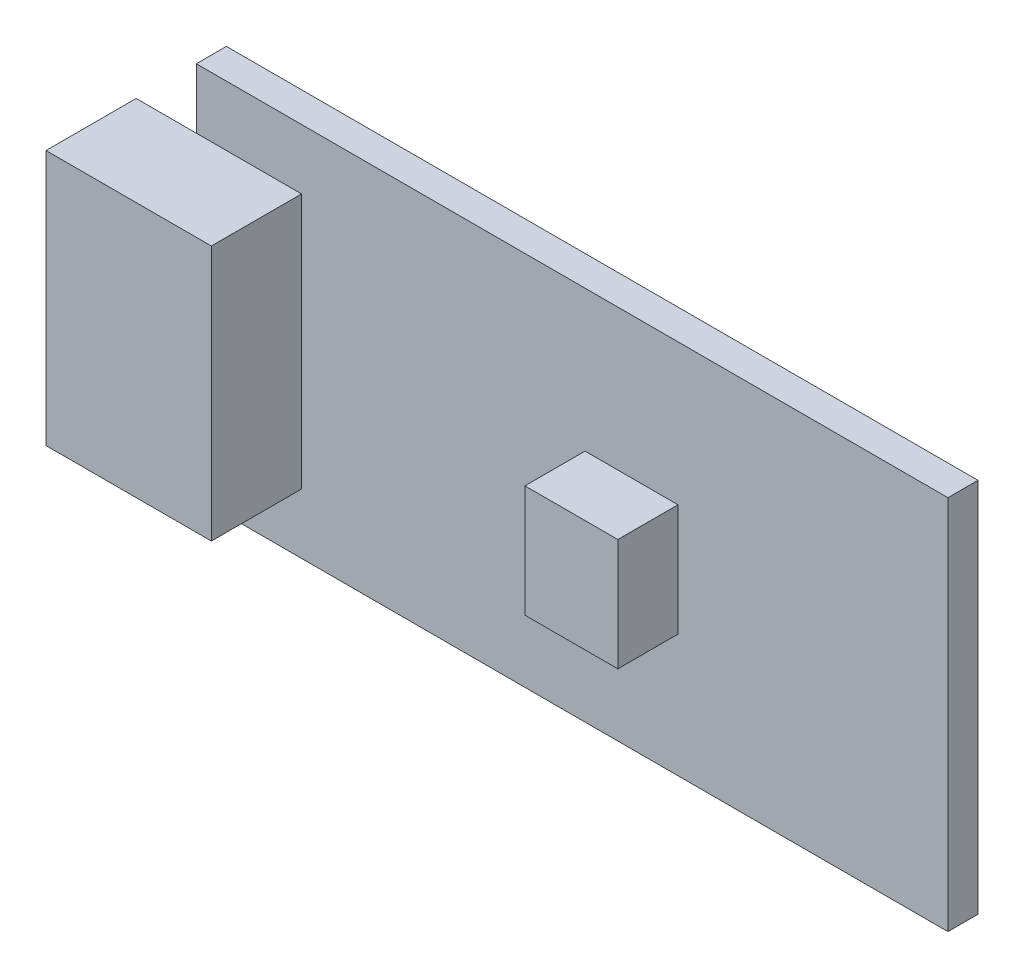
from build123d import *

# Parameters (mm, degrees)
SKIZZE1_W                       = 25
SKIZZE1_H                       = 12.5
SKIZZE1_W_2                     = 3.091607018
SKIZZE1_H_2                     = 3.725771618
AUFSATZ_LINEAR_AUSTRAGEN1_DEPTH = 1
SKIZZE1_2_W                     = 3.091607018
SKIZZE1_2_H                     = 3.725771618
AUFSATZ_LINEAR_AUSTRAGEN2_DEPTH = 3
SKIZZE2_W                       = 5.5
SKIZZE2_H                       = 8.5
AUFSATZ_LINEAR_AUSTRAGEN3_DEPTH = 3


with BuildPart() as part:
    # Skizze1 → Aufsatz-Linear austragen1 (new body)
    with BuildSketch(Plane.XY):
        with Locations((12.5, 6.25)):
            Rectangle(SKIZZE1_W, SKIZZE1_H)
        with Locations((14.475260973, 5.942942992)):
            Rectangle(SKIZZE1_W_2, SKIZZE1_H_2, mode=Mode.SUBTRACT)
    extrude(amount=AUFSATZ_LINEAR_AUSTRAGEN1_DEPTH)

    # Skizze1_2 → Aufsatz-Linear austragen2 (add)
    with BuildSketch(Plane.XY):
        with Locations((14.475260973, 5.942942992)):
            Rectangle(SKIZZE1_2_W, SKIZZE1_2_H)
    extrude(amount=AUFSATZ_LINEAR_AUSTRAGEN2_DEPTH)

    # Skizze2 → Aufsatz-Linear austragen3 (add)
    with BuildSketch(Plane.XY.offset(1)):
        with Locations((0.75, 6.25)):
            Rectangle(SKIZZE2_W, SKIZZE2_H)
    extrude(amount=AUFSATZ_LINEAR_AUSTRAGEN3_DEPTH)


solid = part.part
